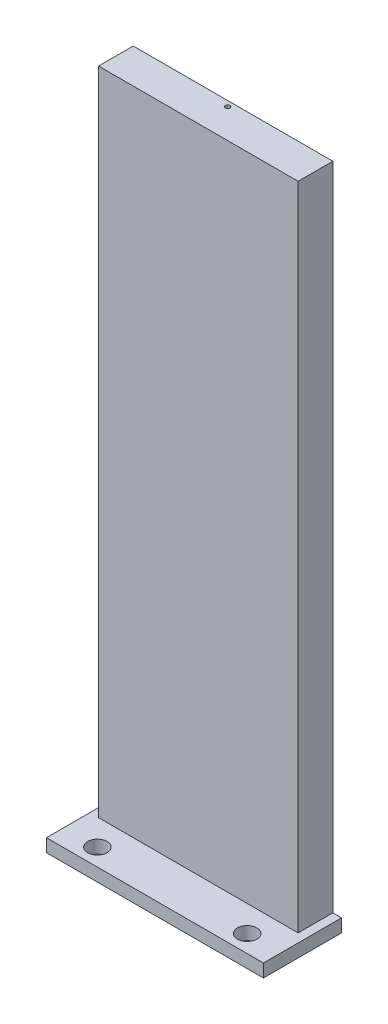
from build123d import *

# Parameters (mm, degrees)
SKETCH1_W                 = 50
SKETCH1_H                 = 8
BOSS_EXTRUDE1_DEPTH       = 3
F_8_CLEARANCE_HOLE1_D     = 4.4958
F_8_CLEARANCE_HOLE1_DEPTH = 17
F_8_CLEARANCE_HOLE1_TIP   = 1.350674586
SKETCH3_W                 = 50
SKETCH3_H                 = 3
BOSS_EXTRUDE2_DEPTH       = 10
SKETCH5_W                 = 46
SKETCH5_H                 = 8
BOSS_EXTRUDE3_DEPTH       = 150
SKETCH6_R                 = 0.5207
CUT_EXTRUDE1_DEPTH        = 30


with BuildPart() as part:
    # Sketch1 → Boss-Extrude1 (new body)
    with BuildSketch(Plane(origin=(0, 0, 0), x_dir=(1, 0, 0), z_dir=(0, 1, 0))):
        with Locations((17.773632998, 0.313559322)):
            Rectangle(SKETCH1_W, SKETCH1_H)
    extrude(amount=BOSS_EXTRUDE1_DEPTH)

    # #8 Clearance Hole1
    with Locations(Plane(origin=(0.523632998, 3, -0.313559322), x_dir=(0, 0, 1), z_dir=(0, 1, 0))):
        with Locations((0, 0), (0, 34.5)):
            Hole(F_8_CLEARANCE_HOLE1_D / 2, depth=F_8_CLEARANCE_HOLE1_DEPTH)
            with Locations((0, 0, -(F_8_CLEARANCE_HOLE1_DEPTH + F_8_CLEARANCE_HOLE1_TIP / 2))):  # 118° drill point
                Cone(0, F_8_CLEARANCE_HOLE1_D / 2, F_8_CLEARANCE_HOLE1_TIP, mode=Mode.SUBTRACT)

    # Sketch3 → Boss-Extrude2 (add)
    with BuildSketch(Plane(origin=(0, 0, -4.313559322), x_dir=(-1, 0, 0), z_dir=(0, 0, -1))):
        with Locations((-17.773632998, 1.5)):
            Rectangle(SKETCH3_W, SKETCH3_H)
    extrude(amount=BOSS_EXTRUDE2_DEPTH)

    # Sketch5 → Boss-Extrude3 (add)
    with BuildSketch(Plane(origin=(0, 3, 0), x_dir=(1, 0, 0), z_dir=(0, 1, 0))):
        with Locations((17.773632998, 10.313559322)):
            Rectangle(SKETCH5_W, SKETCH5_H)
    extrude(amount=BOSS_EXTRUDE3_DEPTH)

    # Sketch6 → Cut-Extrude1 (cut)
    with BuildSketch(Plane(origin=(0, 153, 0), x_dir=(1, 0, 0), z_dir=(0, 1, 0))):
        with Locations((17.773632998, 13.063559322)):
            Circle(SKETCH6_R)
    extrude(amount=-CUT_EXTRUDE1_DEPTH, mode=Mode.SUBTRACT)


solid = part.part
